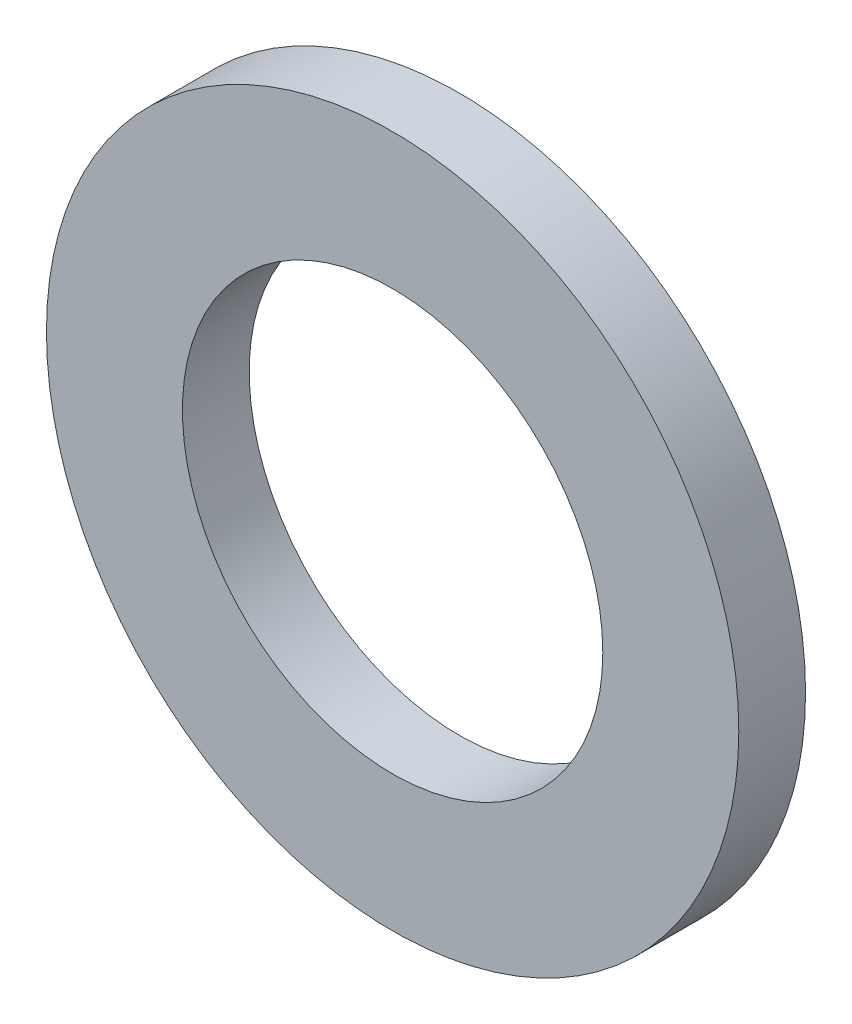
from build123d import *

# Parameters (mm, degrees)
SKETCH1_R           = 14
SKETCH1_R_2         = 8.5
BOSS_EXTRUDE1_DEPTH = 2.7


with BuildPart() as part:
    # Sketch1 → Boss-Extrude1 (new body)
    with BuildSketch(Plane.XY):
        Circle(SKETCH1_R)
        Circle(SKETCH1_R_2, mode=Mode.SUBTRACT)
    extrude(amount=BOSS_EXTRUDE1_DEPTH)


solid = part.part
